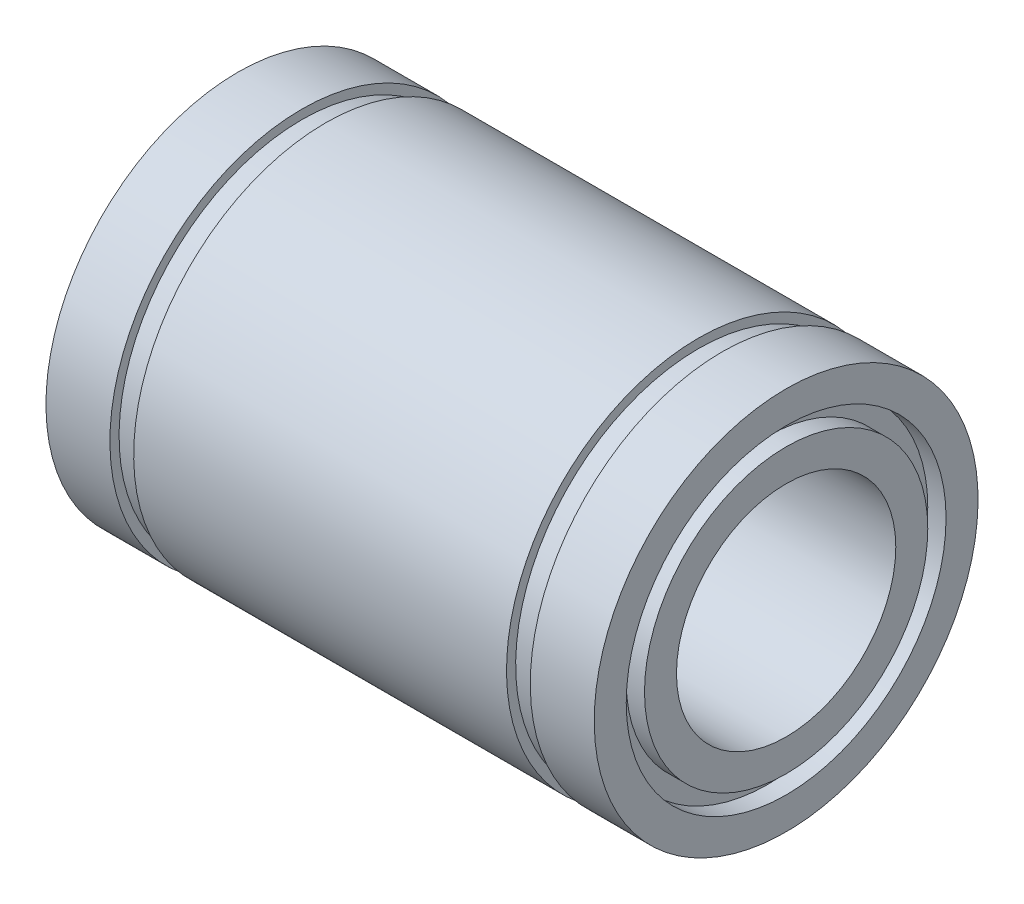
from build123d import *


with BuildPart() as part:
    # Esboço1 → Revolução1 (revolve)
    with BuildSketch(Plane.XY):
        Polygon((-15, 10.5), (-11.5, 10.5), (-11.5, 10), (-10.2, 10), (-10.2, 10.5), (10.2, 10.5), (10.2, 10), (11.5, 10), (11.5, 10.5), (15, 10.5), (15, 8.75), (14, 8.75), (14, 7.75), (15, 7.75), (15, 6), (-15, 6), (-15, 7.75), (-14, 7.75), (-14, 8.75), (-15, 8.75), align=None)
    revolve(axis=Axis((0, 0, 0), (-1, 0, 0)))


solid = part.part
